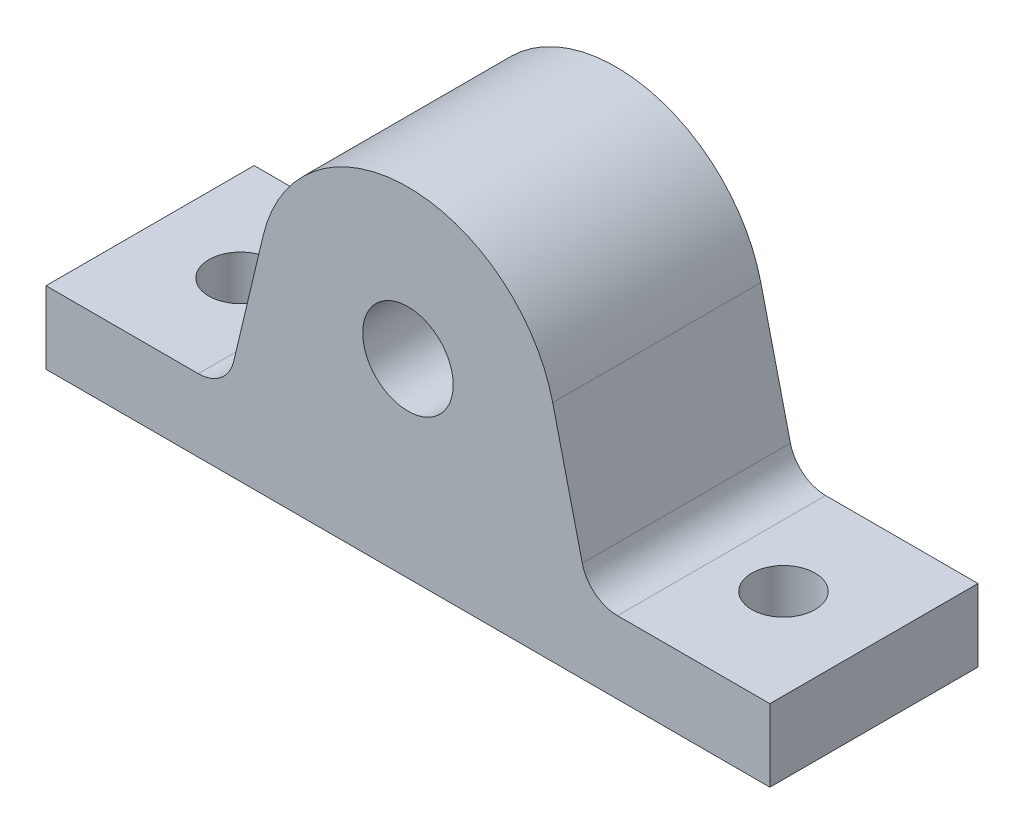
from build123d import *

# Parameters (mm, degrees)
EXTRUDE1_DEPTH     = 18.25625
FILLET1_R          = 6.35
SKETCH3_R          = 7.9375
CUT_EXTRUDE1_DEPTH = 37.5125
SKETCH4_R          = 5.55625
CUT_EXTRUDE2_DEPTH = 13.7


with BuildPart() as part:
    # Sketch1 → Extrude1 (new body, symmetric)
    with BuildSketch(Plane.XY):
        with BuildLine():
            Line((-63.5, 0), (63.5, 0))
            Line((63.5, 0), (63.5, 12.7))
            Line((63.5, 12.7), (31.75, 12.7))
            Line((31.75, 12.7), (25.4, 39.382325452))
            ThreePointArc((25.4, 39.382325452), (0, 59.446883653), (-25.4, 39.382325452))
            Line((-25.4, 39.382325452), (-31.75, 12.7))
            Line((-31.75, 12.7), (-63.5, 12.7))
            Line((-63.5, 12.7), (-63.5, 0))
        make_face()
    extrude(amount=EXTRUDE1_DEPTH, both=True)

    # Fillet1
    fillet1_edges = [part.edges().sort_by_distance(p)[0] for p in [
        (-31.75, 12.7, 0),
        (31.75, 12.7, 0),
    ]]
    fillet(fillet1_edges, radius=FILLET1_R)

    # Sketch3 → Cut-Extrude1 (cut, through all)
    with BuildSketch(Plane.XY.offset(18.25625)):
        with Locations((0, 33.3375)):
            Circle(SKETCH3_R)
    extrude(amount=-CUT_EXTRUDE1_DEPTH, mode=Mode.SUBTRACT)

    # Sketch4 → Cut-Extrude2 (cut, through all)
    with BuildSketch(Plane(origin=(0, 12.7, 0), x_dir=(-1, 0, 0), z_dir=(0, 1, 0))):
        with Locations((-47.625, 0)):
            Circle(SKETCH4_R)
        with Locations((47.625, 0)):
            Circle(SKETCH4_R)
    extrude(amount=-CUT_EXTRUDE2_DEPTH, mode=Mode.SUBTRACT)


solid = part.part
